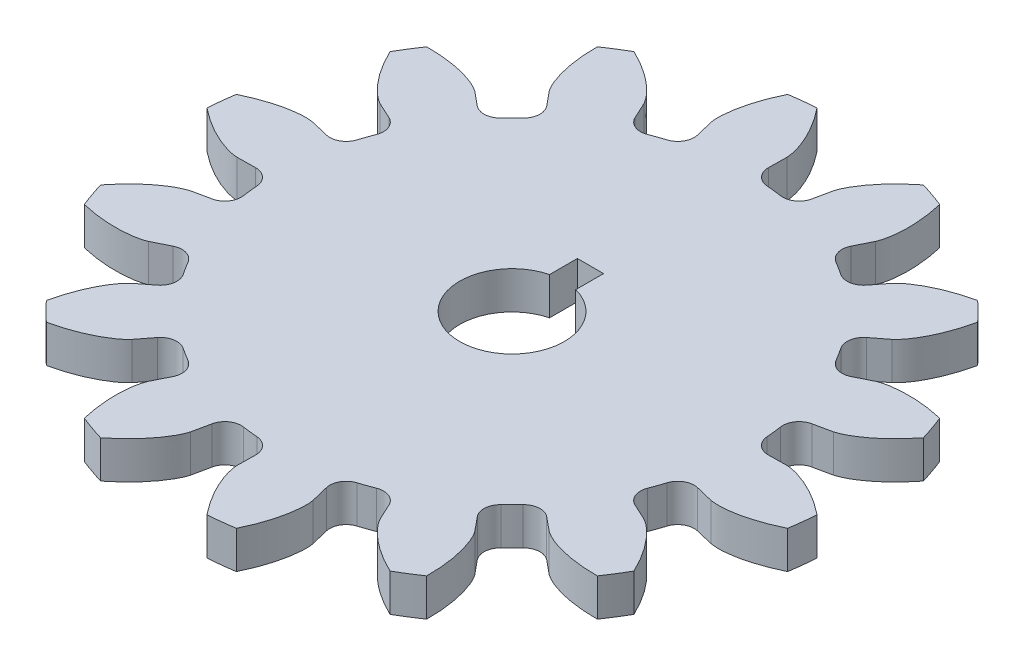
from build123d import *

# Parameters (mm, degrees)
SKETCH5_R                = 28.75
BOSS_EXTRUDE1_DEPTH      = 4.55422
BOSS_EXTRUDE2_DEPTH      = 4.55422
FILLET1_R                = 2
CIRPATTERN1_COUNT        = 14
FILLET1_OF_CIRPATTERN1_R = 2
CUT_EXTRUDE3_DEPTH       = 4.55422


with BuildPart() as part:
    # Sketch5 → Boss-Extrude1 (new body)
    with BuildSketch(Plane(origin=(0, 0, 0), x_dir=(1, 0, 0), z_dir=(0, 1, 0))):
        Circle(SKETCH5_R)
    extrude(amount=BOSS_EXTRUDE1_DEPTH)

    # Sketch4 → Boss-Extrude2 (add)
    with BuildSketch(Plane(origin=(0, 0, 0), x_dir=(1, 0, 0), z_dir=(0, 1, 0))):
        with BuildLine():
            Line((0.490175735, 32.885588776), (0.428485172, 28.746806787))
            ThreePointArc((0.428485172, 28.746806787), (-3.218978688, 28.569226034), (-6.814508448, 27.930717402))
            Line((-6.814508448, 27.930717402), (-7.795617934, 31.952004044))
            add(Edge.make_bspline(
                [(-6.078262691, 39.535486878), (-6.157536711, 39.37327721), (-6.658100738, 38.317317461), (-7.332630654, 36.535565555), (-7.84711573, 34.139421534), (-7.914845195, 32.670663808), (-7.795617934, 31.952004044)],
                knots=[0.287497839, 0.287497839, 0.287497839, 0.287497839, 0.336409615, 0.604082537, 0.803018966, 1, 1, 1, 1], degree=3))
            ThreePointArc((-6.078262691, 39.535486878), (-4.478579044, 39.748488396), (-2.871605509, 39.89679037))
            add(Edge.make_bspline(
                [(-2.871605509, 39.89679037), (-2.758224008, 39.756287766), (-2.035237017, 38.838189107), (-0.981141876, 37.251206469), (0.05363619, 35.02962248), (0.446496878, 33.612760801), (0.490175735, 32.885588776)],
                knots=[0.287497839, 0.287497839, 0.287497839, 0.287497839, 0.336409615, 0.604082537, 0.803018966, 1, 1, 1, 1], degree=3))
        make_face()
    boss_extrude2 = extrude(amount=BOSS_EXTRUDE2_DEPTH)

    # Fillet1
    fillet1_edges = [part.edges().sort_by_distance(p)[0] for p in [
        (0.428485172, 2.27711, -28.746806787),
        (-6.814508448, 2.27711, -27.930717402),
    ]]
    fillet(fillet1_edges, radius=FILLET1_R)

    # CirPattern1: Boss-Extrude2 ×14 about axis
    cirpattern1_axis = Axis((0, 85.871499836, 0), (0, -1, 0))
    for i in range(1, CIRPATTERN1_COUNT):
        add(boss_extrude2.rotate(cirpattern1_axis, i * 360 / CIRPATTERN1_COUNT))

    # Fillet1 of CirPattern1
    fillet1_of_cirpattern1_edges = [part.edges().sort_by_distance(p)[0] for p in [
        (12.858823817, 2.27711, -25.714065218),
        (5.979024141, 2.27711, -28.121411243),
        (22.742314701, 2.27711, -17.588337671),
        (17.588337671, 2.27711, -22.742314701),
        (28.121411243, 2.27711, -5.979024141),
        (25.714065218, 2.27711, -12.858823817),
        (27.930717402, 2.27711, 6.814508448),
        (28.746806787, 2.27711, -0.428485172),
        (22.208002432, 2.27711, 18.258344065),
        (26.085890715, 2.27711, 12.086720216),
        (12.086720216, 2.27711, 26.085890715),
        (18.258344065, 2.27711, 22.208002432),
        (-0.428485172, 2.27711, 28.746806787),
        (6.814508448, 2.27711, 27.930717402),
        (-12.858823817, 2.27711, 25.714065218),
        (-5.979024141, 2.27711, 28.121411243),
        (-22.742314701, 2.27711, 17.588337671),
        (-17.588337671, 2.27711, 22.742314701),
        (-28.121411243, 2.27711, 5.979024141),
        (-25.714065218, 2.27711, 12.858823817),
        (-27.930717402, 2.27711, -6.814508448),
        (-28.746806787, 2.27711, 0.428485172),
        (-22.208002432, 2.27711, -18.258344065),
        (-26.085890715, 2.27711, -12.086720216),
        (-12.086720216, 2.27711, -26.085890715),
        (-18.258344065, 2.27711, -22.208002432),
    ]]
    fillet(fillet1_of_cirpattern1_edges, radius=FILLET1_OF_CIRPATTERN1_R)

    # Sketch6 → Cut-Extrude3 (cut)
    with BuildSketch(Plane(origin=(0, 0, 0), x_dir=(1, 0, 0), z_dir=(0, 1, 0))):
        with BuildLine():
            Line((-1.5875, 9.525), (1.5875, 9.525))
            Line((1.5875, 9.525), (1.5875, 6.148361062))
            ThreePointArc((1.5875, 6.148361062), (0, -6.35), (-1.5875, 6.148361062))
            Line((-1.5875, 6.148361062), (-1.5875, 9.525))
        make_face()
    extrude(amount=CUT_EXTRUDE3_DEPTH, mode=Mode.SUBTRACT)


solid = part.part
